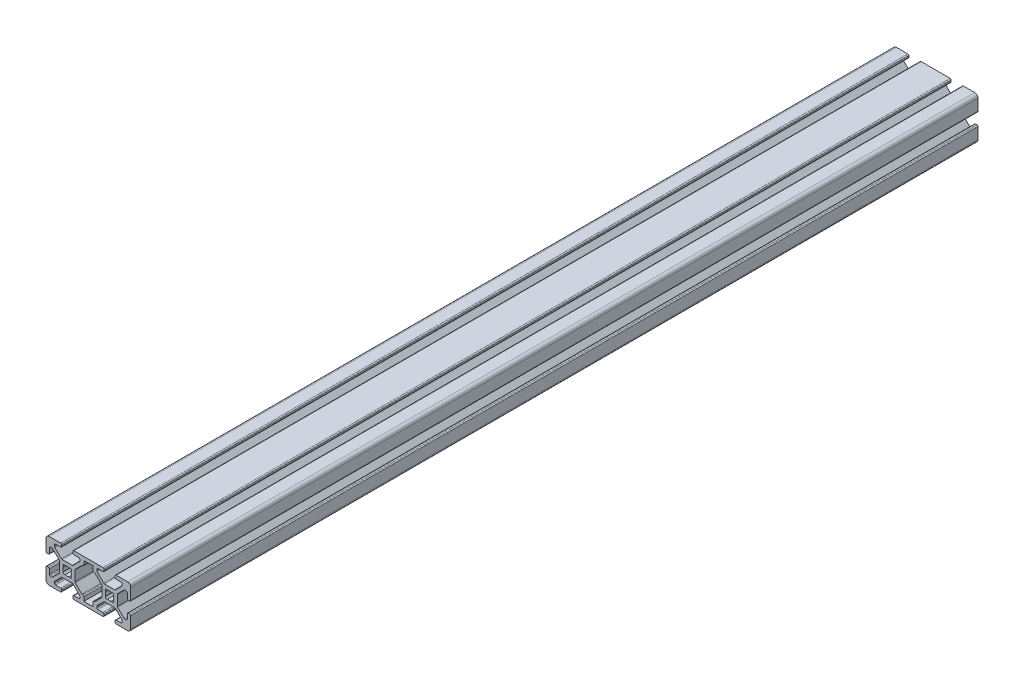
from build123d import *

# Parameters (mm, degrees)
BOSS_EXTRUDE1_DEPTH = 400


with BuildPart() as part:
    # Sketch1 → Boss-Extrude1 (new body)
    with BuildSketch(Plane.XY):
        with BuildLine():
            Line((-5.847983186, -6.908643358), (-2.746356642, -3.807016814))
            ThreePointArc((-2.746356642, -3.807016814), (-2.58351338, -3.698208425), (-2.391426656, -3.66))
            Line((-2.391426656, -3.66), (2.391426656, -3.66))
            ThreePointArc((2.391426656, -3.66), (2.58351338, -3.698208425), (2.746356642, -3.807016814))
            Line((2.746356642, -3.807016814), (5.847983186, -6.908643358))
            ThreePointArc((5.847983186, -6.908643358), (5.956791575, -7.07148662), (5.995, -7.263573344))
            Line((5.995, -7.263573344), (5.995, -7.858053199))
            ThreePointArc((5.995, -7.858053199), (5.847983186, -8.212983186), (5.493053199, -8.36))
            Line((5.493053199, -8.36), (3.131946801, -8.36))
            ThreePointArc((3.131946801, -8.36), (2.777016814, -8.507016814), (2.63, -8.861946801))
            Line((2.63, -8.861946801), (2.63, -9.498053199))
            ThreePointArc((2.63, -9.498053199), (2.777016814, -9.852983186), (3.131946801, -10))
            Line((3.131946801, -10), (8.5, -10))
            Line((8.5, -10), (11.5, -10))
            Line((11.5, -10), (16.868053199, -10))
            ThreePointArc((16.868053199, -10), (17.222983186, -9.852983186), (17.37, -9.498053199))
            Line((17.37, -9.498053199), (17.37, -8.861946801))
            ThreePointArc((17.37, -8.861946801), (17.222983186, -8.507016814), (16.868053199, -8.36))
            Line((16.868053199, -8.36), (14.506946801, -8.36))
            ThreePointArc((14.506946801, -8.36), (14.152016814, -8.212983186), (14.005, -7.858053199))
            Line((14.005, -7.858053199), (14.005, -7.263573344))
            ThreePointArc((14.005, -7.263573344), (14.043208425, -7.07148662), (14.152016814, -6.908643358))
            Line((14.152016814, -6.908643358), (17.253643358, -3.807016814))
            ThreePointArc((17.253643358, -3.807016814), (17.41648662, -3.698208425), (17.608573344, -3.66))
            Line((17.608573344, -3.66), (22.391426656, -3.66))
            ThreePointArc((22.391426656, -3.66), (22.58351338, -3.698208425), (22.746356642, -3.807016814))
            Line((22.746356642, -3.807016814), (25.847983186, -6.908643358))
            ThreePointArc((25.847983186, -6.908643358), (25.956791575, -7.07148662), (25.995, -7.263573344))
            Line((25.995, -7.263573344), (25.995, -7.858053199))
            ThreePointArc((25.995, -7.858053199), (25.847983186, -8.212983186), (25.493053199, -8.36))
            Line((25.493053199, -8.36), (23.131946801, -8.36))
            ThreePointArc((23.131946801, -8.36), (22.777016814, -8.507016814), (22.63, -8.861946801))
            Line((22.63, -8.861946801), (22.63, -9.498053199))
            ThreePointArc((22.63, -9.498053199), (22.777016814, -9.852983186), (23.131946801, -10))
            Line((23.131946801, -10), (28.5, -10))
            ThreePointArc((28.5, -10), (29.560660172, -9.560660172), (30, -8.5))
            Line((30, -8.5), (30, -3.131946801))
            ThreePointArc((30, -3.131946801), (29.852983186, -2.777016814), (29.498053199, -2.63))
            Line((29.498053199, -2.63), (28.861946801, -2.63))
            ThreePointArc((28.861946801, -2.63), (28.507016814, -2.777016814), (28.36, -3.131946801))
            Line((28.36, -3.131946801), (28.36, -5.493053199))
            ThreePointArc((28.36, -5.493053199), (28.212983186, -5.847983186), (27.858053199, -5.995))
            Line((27.858053199, -5.995), (27.263573344, -5.995))
            ThreePointArc((27.263573344, -5.995), (27.07148662, -5.956791575), (26.908643358, -5.847983186))
            Line((26.908643358, -5.847983186), (23.807016814, -2.746356642))
            ThreePointArc((23.807016814, -2.746356642), (23.698208425, -2.58351338), (23.66, -2.391426656))
            Line((23.66, -2.391426656), (23.66, 2.391426656))
            ThreePointArc((23.66, 2.391426656), (23.698208425, 2.58351338), (23.807016814, 2.746356642))
            Line((23.807016814, 2.746356642), (26.908643358, 5.847983186))
            ThreePointArc((26.908643358, 5.847983186), (27.07148662, 5.956791575), (27.263573344, 5.995))
            Line((27.263573344, 5.995), (27.858053199, 5.995))
            ThreePointArc((27.858053199, 5.995), (28.212983186, 5.847983186), (28.36, 5.493053199))
            Line((28.36, 5.493053199), (28.36, 3.131946801))
            ThreePointArc((28.36, 3.131946801), (28.507016814, 2.777016814), (28.861946801, 2.63))
            Line((28.861946801, 2.63), (29.498053199, 2.63))
            ThreePointArc((29.498053199, 2.63), (29.852983186, 2.777016814), (30, 3.131946801))
            Line((30, 3.131946801), (30, 8.5))
            ThreePointArc((30, 8.5), (29.560660172, 9.560660172), (28.5, 10))
            Line((28.5, 10), (23.131946801, 10))
            ThreePointArc((23.131946801, 10), (22.777016814, 9.852983186), (22.63, 9.498053199))
            Line((22.63, 9.498053199), (22.63, 8.861946801))
            ThreePointArc((22.63, 8.861946801), (22.777016814, 8.507016814), (23.131946801, 8.36))
            Line((23.131946801, 8.36), (25.493053199, 8.36))
            ThreePointArc((25.493053199, 8.36), (25.847983186, 8.212983186), (25.995, 7.858053199))
            Line((25.995, 7.858053199), (25.995, 7.263573344))
            ThreePointArc((25.995, 7.263573344), (25.956791575, 7.07148662), (25.847983186, 6.908643358))
            Line((25.847983186, 6.908643358), (22.746356642, 3.807016814))
            ThreePointArc((22.746356642, 3.807016814), (22.58351338, 3.698208425), (22.391426656, 3.66))
            Line((22.391426656, 3.66), (17.608573344, 3.66))
            ThreePointArc((17.608573344, 3.66), (17.41648662, 3.698208425), (17.253643358, 3.807016814))
            Line((17.253643358, 3.807016814), (14.152016814, 6.908643358))
            ThreePointArc((14.152016814, 6.908643358), (14.043208425, 7.07148662), (14.005, 7.263573344))
            Line((14.005, 7.263573344), (14.005, 7.858053199))
            ThreePointArc((14.005, 7.858053199), (14.152016814, 8.212983186), (14.506946801, 8.36))
            Line((14.506946801, 8.36), (16.868053199, 8.36))
            ThreePointArc((16.868053199, 8.36), (17.222983186, 8.507016814), (17.37, 8.861946801))
            Line((17.37, 8.861946801), (17.37, 9.498053199))
            ThreePointArc((17.37, 9.498053199), (17.222983186, 9.852983186), (16.868053199, 10))
            Line((16.868053199, 10), (11.5, 10))
            Line((11.5, 10), (8.5, 10))
            Line((8.5, 10), (3.131946801, 10))
            ThreePointArc((3.131946801, 10), (2.777016814, 9.852983186), (2.63, 9.498053199))
            Line((2.63, 9.498053199), (2.63, 8.861946801))
            ThreePointArc((2.63, 8.861946801), (2.777016814, 8.507016814), (3.131946801, 8.36))
            Line((3.131946801, 8.36), (5.493053199, 8.36))
            ThreePointArc((5.493053199, 8.36), (5.847983186, 8.212983186), (5.995, 7.858053199))
            Line((5.995, 7.858053199), (5.995, 7.263573344))
            ThreePointArc((5.995, 7.263573344), (5.956791575, 7.07148662), (5.847983186, 6.908643358))
            Line((5.847983186, 6.908643358), (2.746356642, 3.807016814))
            ThreePointArc((2.746356642, 3.807016814), (2.58351338, 3.698208425), (2.391426656, 3.66))
            Line((2.391426656, 3.66), (-2.391426656, 3.66))
            ThreePointArc((-2.391426656, 3.66), (-2.58351338, 3.698208425), (-2.746356642, 3.807016814))
            Line((-2.746356642, 3.807016814), (-5.847983186, 6.908643358))
            ThreePointArc((-5.847983186, 6.908643358), (-5.956791575, 7.07148662), (-5.995, 7.263573344))
            Line((-5.995, 7.263573344), (-5.995, 7.858053199))
            ThreePointArc((-5.995, 7.858053199), (-5.847983186, 8.212983186), (-5.493053199, 8.36))
            Line((-5.493053199, 8.36), (-3.131946801, 8.36))
            ThreePointArc((-3.131946801, 8.36), (-2.777016814, 8.507016814), (-2.63, 8.861946801))
            Line((-2.63, 8.861946801), (-2.63, 9.498053199))
            ThreePointArc((-2.63, 9.498053199), (-2.777016814, 9.852983186), (-3.131946801, 10))
            Line((-3.131946801, 10), (-8.36, 10))
            Line((-8.36, 10), (-8.5, 10))
            ThreePointArc((-8.5, 10), (-9.560660172, 9.560660172), (-10, 8.5))
            Line((-10, 8.5), (-10, 3.131946801))
            ThreePointArc((-10, 3.131946801), (-9.852983186, 2.777016814), (-9.498053199, 2.63))
            Line((-9.498053199, 2.63), (-8.861946801, 2.63))
            ThreePointArc((-8.861946801, 2.63), (-8.507016814, 2.777016814), (-8.36, 3.131946801))
            Line((-8.36, 3.131946801), (-8.36, 5.493053199))
            ThreePointArc((-8.36, 5.493053199), (-8.212983186, 5.847983186), (-7.858053199, 5.995))
            Line((-7.858053199, 5.995), (-7.263573344, 5.995))
            ThreePointArc((-7.263573344, 5.995), (-7.07148662, 5.956791575), (-6.908643358, 5.847983186))
            Line((-6.908643358, 5.847983186), (-3.807016814, 2.746356642))
            ThreePointArc((-3.807016814, 2.746356642), (-3.698208425, 2.58351338), (-3.66, 2.391426656))
            Line((-3.66, 2.391426656), (-3.66, -2.391426656))
            ThreePointArc((-3.66, -2.391426656), (-3.698208425, -2.58351338), (-3.807016814, -2.746356642))
            Line((-3.807016814, -2.746356642), (-6.908643358, -5.847983186))
            ThreePointArc((-6.908643358, -5.847983186), (-7.07148662, -5.956791575), (-7.263573344, -5.995))
            Line((-7.263573344, -5.995), (-7.858053199, -5.995))
            ThreePointArc((-7.858053199, -5.995), (-8.212983186, -5.847983186), (-8.36, -5.493053199))
            Line((-8.36, -5.493053199), (-8.36, -3.131946801))
            ThreePointArc((-8.36, -3.131946801), (-8.507016814, -2.777016814), (-8.861946801, -2.63))
            Line((-8.861946801, -2.63), (-9.498053199, -2.63))
            ThreePointArc((-9.498053199, -2.63), (-9.852983186, -2.777016814), (-10, -3.131946801))
            Line((-10, -3.131946801), (-10, -8.5))
            ThreePointArc((-10, -8.5), (-9.560660172, -9.560660172), (-8.5, -10))
            Line((-8.5, -10), (-3.131946801, -10))
            ThreePointArc((-3.131946801, -10), (-2.777016814, -9.852983186), (-2.63, -9.498053199))
            Line((-2.63, -9.498053199), (-2.63, -8.861946801))
            ThreePointArc((-2.63, -8.861946801), (-2.777016814, -8.507016814), (-3.131946801, -8.36))
            Line((-3.131946801, -8.36), (-5.493053199, -8.36))
            ThreePointArc((-5.493053199, -8.36), (-5.847983186, -8.212983186), (-5.995, -7.858053199))
            Line((-5.995, -7.858053199), (-5.995, -7.263573344))
            ThreePointArc((-5.995, -7.263573344), (-5.956791575, -7.07148662), (-5.847983186, -6.908643358))
        make_face()
        with BuildLine():
            ThreePointArc((-1.767678053, -0.935582333), (-2, 0), (-1.767678053, 0.935582333))
            ThreePointArc((-1.767678053, 0.935582333), (-1.834942097, 1.834942097), (-0.935582333, 1.767678053))
            ThreePointArc((-0.935582333, 1.767678053), (0, 2), (0.935582333, 1.767678053))
            ThreePointArc((0.935582333, 1.767678053), (1.834942097, 1.834942097), (1.767678053, 0.935582333))
            ThreePointArc((1.767678053, 0.935582333), (2, 0), (1.767678053, -0.935582333))
            ThreePointArc((1.767678053, -0.935582333), (1.834942097, -1.834942097), (0.935582333, -1.767678053))
            ThreePointArc((0.935582333, -1.767678053), (0, -2), (-0.935582333, -1.767678053))
            ThreePointArc((-0.935582333, -1.767678053), (-1.834942097, -1.834942097), (-1.767678053, -0.935582333))
        make_face(mode=Mode.SUBTRACT)
        with BuildLine():
            Line((7.858053199, -8.36), (7.858053199, -6.495))
            ThreePointArc((7.858053199, -6.495), (7.71160659, -6.141446609), (7.358053199, -5.995))
            Line((7.358053199, -5.995), (7.263573344, -5.995))
            ThreePointArc((7.263573344, -5.995), (7.07148662, -5.956791575), (6.908643358, -5.847983186))
            Line((6.908643358, -5.847983186), (3.807016814, -2.746356642))
            ThreePointArc((3.807016814, -2.746356642), (3.698208425, -2.58351338), (3.66, -2.391426656))
            Line((3.66, -2.391426656), (3.66, 2.391426656))
            ThreePointArc((3.66, 2.391426656), (3.698208425, 2.58351338), (3.807016814, 2.746356642))
            Line((3.807016814, 2.746356642), (6.908643358, 5.847983186))
            ThreePointArc((6.908643358, 5.847983186), (7.07148662, 5.956791575), (7.263573344, 5.995))
            Line((7.263573344, 5.995), (7.358053199, 5.995))
            ThreePointArc((7.358053199, 5.995), (7.71160659, 6.141446609), (7.858053199, 6.495))
            Line((7.858053199, 6.495), (7.858053199, 8.36))
            Line((7.858053199, 8.36), (8.36, 8.36))
            Line((8.36, 8.36), (10, 8.36))
            Line((10, 8.36), (12.141946801, 8.36))
            Line((12.141946801, 8.36), (12.141946801, 6.495))
            ThreePointArc((12.141946801, 6.495), (12.28839341, 6.141446609), (12.641946801, 5.995))
            Line((12.641946801, 5.995), (12.736426656, 5.995))
            ThreePointArc((12.736426656, 5.995), (12.92851338, 5.956791575), (13.091356642, 5.847983186))
            Line((13.091356642, 5.847983186), (16.192983186, 2.746356642))
            ThreePointArc((16.192983186, 2.746356642), (16.301791575, 2.58351338), (16.34, 2.391426656))
            Line((16.34, 2.391426656), (16.34, -2.391426656))
            ThreePointArc((16.34, -2.391426656), (16.301791575, -2.58351338), (16.192983186, -2.746356642))
            Line((16.192983186, -2.746356642), (13.091356642, -5.847983186))
            ThreePointArc((13.091356642, -5.847983186), (12.92851338, -5.956791575), (12.736426656, -5.995))
            Line((12.736426656, -5.995), (12.641946801, -5.995))
            ThreePointArc((12.641946801, -5.995), (12.28839341, -6.141446609), (12.141946801, -6.495))
            Line((12.141946801, -6.495), (12.141946801, -8.36))
            Line((12.141946801, -8.36), (7.858053199, -8.36))
        make_face(mode=Mode.SUBTRACT)
        with BuildLine():
            ThreePointArc((18.232321947, -0.935582333), (18, 0), (18.232321947, 0.935582333))
            ThreePointArc((18.232321947, 0.935582333), (18.165057903, 1.834942097), (19.064417667, 1.767678053))
            ThreePointArc((19.064417667, 1.767678053), (20, 2), (20.935582333, 1.767678053))
            ThreePointArc((20.935582333, 1.767678053), (21.834942097, 1.834942097), (21.767678053, 0.935582333))
            ThreePointArc((21.767678053, 0.935582333), (22, 0), (21.767678053, -0.935582333))
            ThreePointArc((21.767678053, -0.935582333), (21.834942097, -1.834942097), (20.935582333, -1.767678053))
            ThreePointArc((20.935582333, -1.767678053), (20, -2), (19.064417667, -1.767678053))
            ThreePointArc((19.064417667, -1.767678053), (18.165057903, -1.834942097), (18.232321947, -0.935582333))
        make_face(mode=Mode.SUBTRACT)
    extrude(amount=BOSS_EXTRUDE1_DEPTH)


solid = part.part
